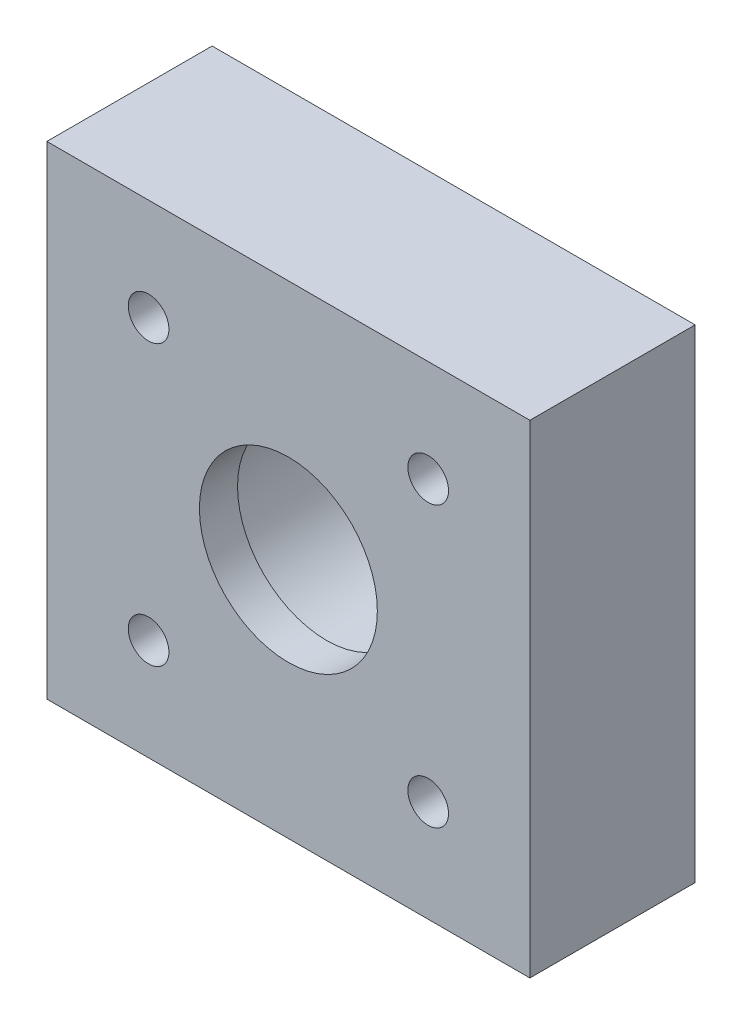
from build123d import *

# Parameters (mm, degrees)
SKETCH1_W                   = 19
SKETCH1_H                   = 19
SKETCH1_R                   = 3.5
BOSS_EXTRUDE1_DEPTH         = 3.25
TAP_DRILL_FOR_M2_TAP1_D     = 1.6
TAP_DRILL_FOR_M2_TAP1_DEPTH = 11.5
SKETCH4_R                   = 4
CUT_EXTRUDE1_DEPTH          = 5


with BuildPart() as part:
    # Sketch1 → Boss-Extrude1 (new body, symmetric)
    with BuildSketch(Plane.XY):
        Rectangle(SKETCH1_W, SKETCH1_H)
        Circle(SKETCH1_R, mode=Mode.SUBTRACT)
    extrude(amount=BOSS_EXTRUDE1_DEPTH, both=True)

    # Tap Drill for M2 Tap1
    with Locations(Plane.XY.offset(3.25)):
        with Locations((-5.5, 5.5), (-5.5, -5.5), (5.5, 5.5), (5.5, -5.5)):
            Hole(TAP_DRILL_FOR_M2_TAP1_D / 2, depth=TAP_DRILL_FOR_M2_TAP1_DEPTH)

    # Sketch4 → Cut-Extrude1 (cut)
    with BuildSketch(Plane(origin=(0, 0, -3.25), x_dir=(-1, 0, 0), z_dir=(0, 0, -1))):
        Circle(SKETCH4_R)
    extrude(amount=-CUT_EXTRUDE1_DEPTH, mode=Mode.SUBTRACT)


solid = part.part
